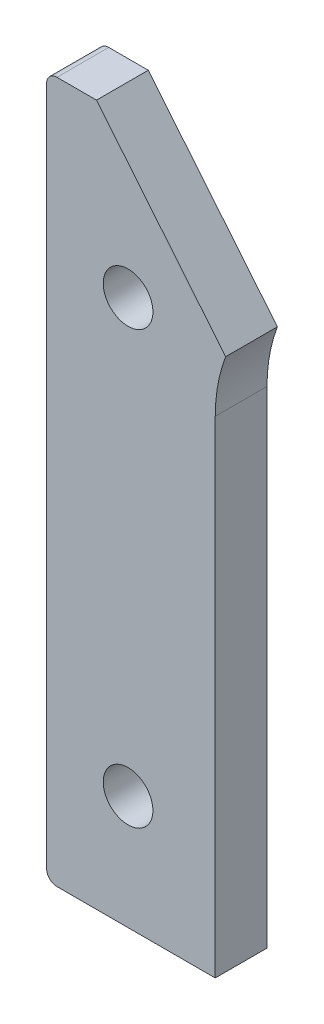
from build123d import *

# Parameters (mm, degrees)
SKETCH1_R           = 3.048
BOSS_EXTRUDE2_DEPTH = 6.35


with BuildPart() as part:
    # Sketch1 → Boss-Extrude2 (new body)
    with BuildSketch(Plane.XY):
        with BuildLine():
            ThreePointArc((-19.685, 0), (-19.36354027, 3.542955436), (-18.409660074, 6.970196624))
            Line((-18.409660074, 6.970196624), (-34.253888671, 26.312396902))
            Line((-34.253888671, 26.312396902), (-39.107436935, 26.312396902))
            ThreePointArc((-39.107436935, 26.312396902), (-40.005462547, 25.940422514), (-40.377436935, 25.042396902))
            Line((-40.377436935, 25.042396902), (-40.377436935, -58.42))
            ThreePointArc((-40.377436935, -58.42), (-40.005462547, -59.318025612), (-39.107436935, -59.69))
            Line((-39.107436935, -59.69), (-19.685, -59.69))
            Line((-19.685, -59.69), (-19.685, 0))
        make_face()
        with Locations((-30.382536935, 7.262396902)):
            Circle(SKETCH1_R, mode=Mode.SUBTRACT)
        with Locations((-30.382536935, -45.72)):
            Circle(SKETCH1_R, mode=Mode.SUBTRACT)
    extrude(amount=BOSS_EXTRUDE2_DEPTH)


solid = part.part
